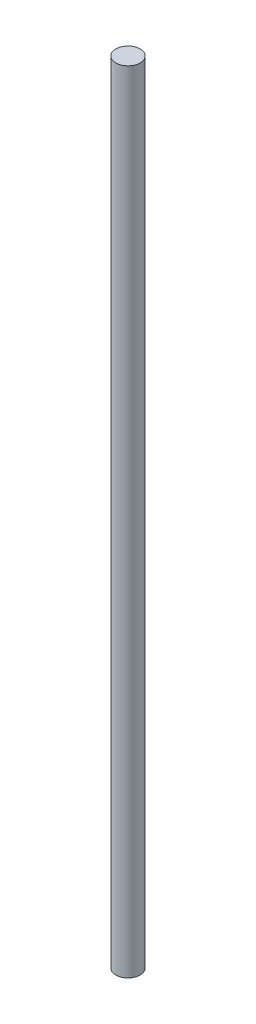
from build123d import *

# Parameters (mm, degrees)
SKETCH1_R           = 4
BOSS_EXTRUDE1_DEPTH = 260


with BuildPart() as part:
    # Sketch1 → Boss-Extrude1 (new body)
    with BuildSketch(Plane(origin=(0, 0, 0), x_dir=(1, 0, 0), z_dir=(0, 1, 0))):
        Circle(SKETCH1_R)
    extrude(amount=BOSS_EXTRUDE1_DEPTH)


solid = part.part
